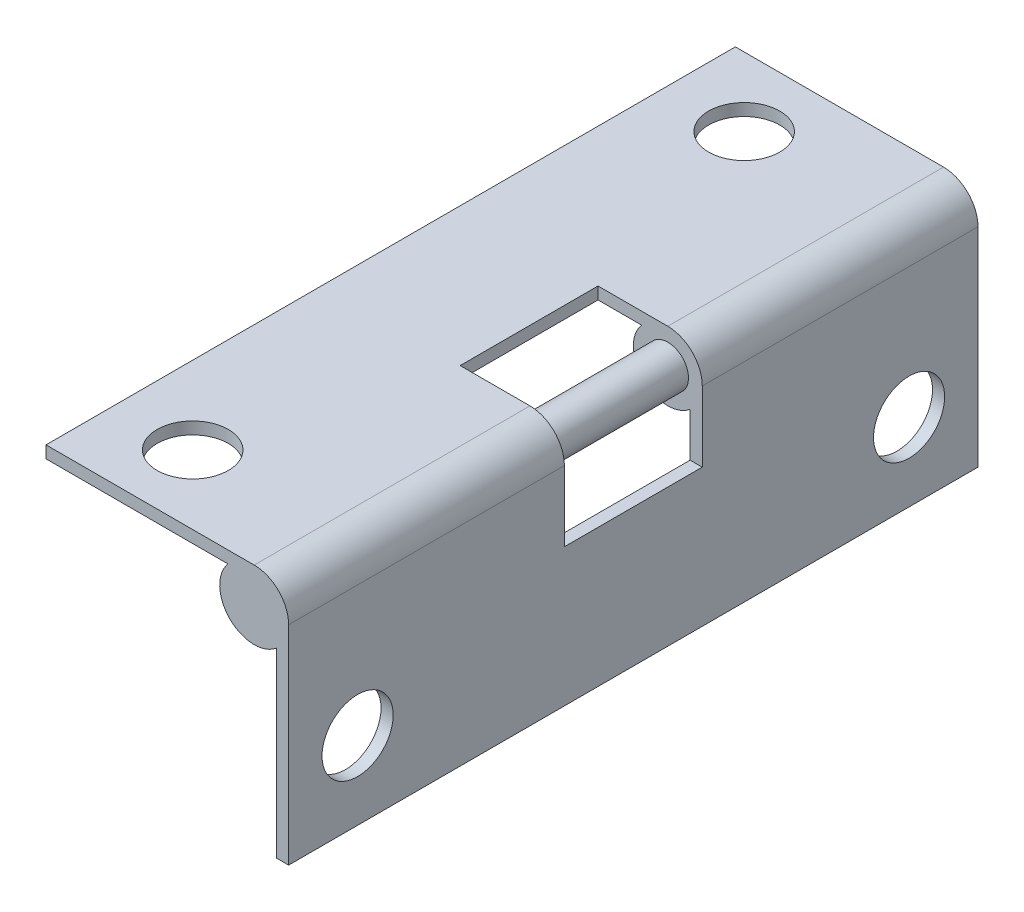
from build123d import *

# Parameters (mm, degrees)
BOSS_EXTRUDE1_DEPTH = 31.75
SKETCH2_R           = 1.6383
SKETCH2_W           = 3.2131
SKETCH2_H           = 6.35
SKETCH2_W_2         = 1.5875
CUT_EXTRUDE1_DEPTH  = 4.826
SKETCH3_R           = 1.6383
CUT_EXTRUDE2_DEPTH  = 12.176
BOSS_EXTRUDE2_REACH = 21.05
SKETCH4_R           = 0.9525


with BuildPart() as part:
    # Sketch1 → Boss-Extrude1 (new body)
    with BuildSketch(Plane.XY):
        with BuildLine():
            Line((0, 1.5875), (-9.5885, 1.5875))
            Line((-9.5885, 1.5875), (-9.5885, 1.0287))
            Line((-9.5885, 1.0287), (-1.209104032, 1.0287))
            ThreePointArc((-1.209104032, 1.0287), (-1.122532015, -1.122532015), (1.0287, -1.209104032))
            Line((1.0287, -1.209104032), (1.0287, -9.5885))
            Line((1.0287, -9.5885), (1.5875, -9.5885))
            Line((1.5875, -9.5885), (1.5875, 0))
            ThreePointArc((1.5875, 0), (1.122532015, 1.122532015), (0, 1.5875))
        make_face()
    extrude(amount=BOSS_EXTRUDE1_DEPTH)

    # Sketch2 → Cut-Extrude1 (cut)
    with BuildSketch(Plane(origin=(0, 1.5875, 0), x_dir=(1, 0, 0), z_dir=(0, 1, 0))):
        with Locations((-6.0071, -28.575)):
            Circle(SKETCH2_R)
        with Locations((-6.0071, -3.175)):
            Circle(SKETCH2_R)
        with Locations((-1.60655, -15.875)):
            Rectangle(SKETCH2_W, SKETCH2_H)
        with Locations((0.79375, -15.875)):
            Rectangle(SKETCH2_W_2, SKETCH2_H)
    extrude(amount=-CUT_EXTRUDE1_DEPTH, mode=Mode.SUBTRACT)

    # Sketch3 → Cut-Extrude2 (cut, through all)
    with BuildSketch(Plane(origin=(1.5875, 0, 0), x_dir=(0, 0, -1), z_dir=(1, 0, 0))):
        with Locations((-28.575, -6.0071)):
            Circle(SKETCH3_R)
        with Locations((-3.175, -6.0071)):
            Circle(SKETCH3_R)
    extrude(amount=-CUT_EXTRUDE2_DEPTH, mode=Mode.SUBTRACT)

    # Sketch4 → Boss-Extrude2 (add, up to next)
    with BuildSketch(Plane(origin=(0, 0, 19.05), x_dir=(-1, 0, 0), z_dir=(0, 0, -1)), mode=Mode.PRIVATE) as boss_extrude2_sk1:
        Circle(SKETCH4_R)
    boss_extrude2_tool1 = extrude(boss_extrude2_sk1.sketch, amount=BOSS_EXTRUDE2_REACH, mode=Mode.PRIVATE) - part.part
    add(boss_extrude2_tool1.solids().sort_by_distance((0, 0, 19.05))[0])


solid = part.part
